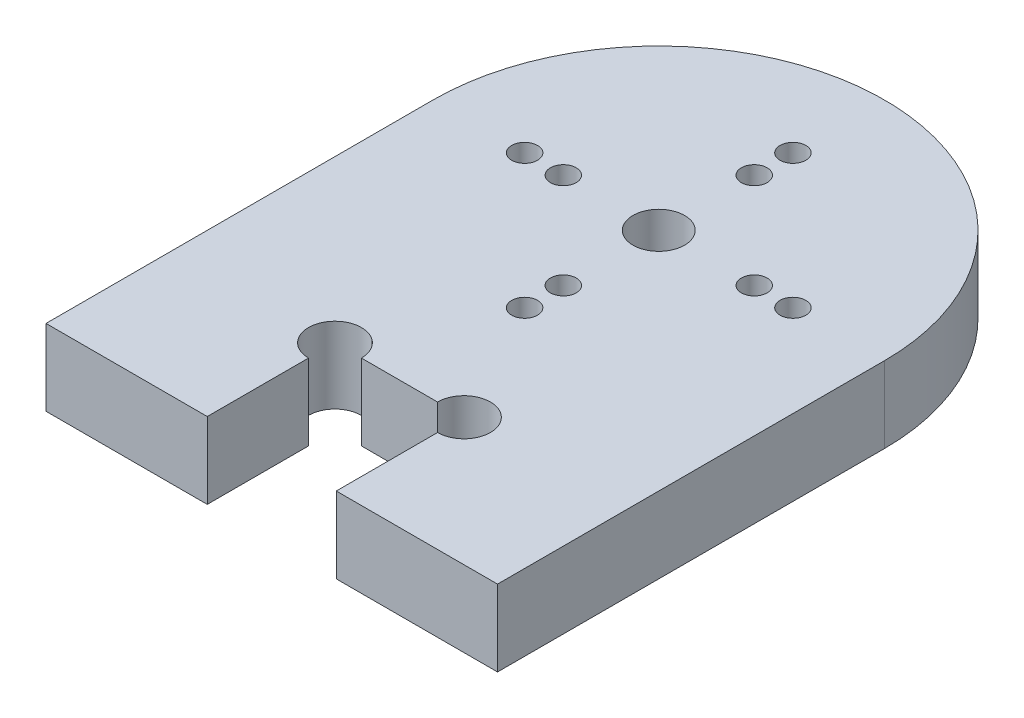
from build123d import *

# Parameters (mm, degrees)
SKETCH1_R           = 1
BOSS_EXTRUDE1_DEPTH = 5.9
SKETCH2_W           = 10
SKETCH2_H           = 11.8
CUT_EXTRUDE1_DEPTH  = 10
SKETCH3_W           = 12.5
SKETCH3_H           = 5.9
BOSS_EXTRUDE2_DEPTH = 5
CUT_EXTRUDE2_REACH  = 7.9
SKETCH4_R           = 2.05


with BuildPart() as part:
    # Sketch1 → Boss-Extrude1 (new body)
    with BuildSketch(Plane(origin=(0, 0, 0), x_dir=(1, 0, 0), z_dir=(0, 1, 0))):
        with BuildLine():
            ThreePointArc((9.4, 12.5), (10.4, 13.5), (11.4, 12.5))
            Line((11.4, 12.5), (17.5, 12.5))
            ThreePointArc((17.5, 12.5), (0, 30), (-17.5, 12.5))
            Line((-17.5, 12.5), (-11.4, 12.5))
            ThreePointArc((-11.4, 12.5), (-10.4, 13.5), (-9.4, 12.5))
            Line((-9.4, 12.5), (-8.4, 12.5))
            ThreePointArc((-8.4, 12.5), (-7.4, 13.5), (-6.4, 12.5))
            Line((-6.4, 12.5), (-2, 12.5))
            ThreePointArc((-2, 12.5), (0, 14.5), (2, 12.5))
            Line((2, 12.5), (6.4, 12.5))
            ThreePointArc((6.4, 12.5), (7.4, 13.5), (8.4, 12.5))
            Line((8.4, 12.5), (9.4, 12.5))
        make_face()
        with Locations((0, 19.9)):
            Circle(SKETCH1_R, mode=Mode.SUBTRACT)
        with Locations((0, 22.9)):
            Circle(SKETCH1_R, mode=Mode.SUBTRACT)
        with BuildLine():
            Line((17.5, 12.5), (11.4, 12.5))
            ThreePointArc((11.4, 12.5), (10.4, 11.5), (9.4, 12.5))
            Line((9.4, 12.5), (8.4, 12.5))
            ThreePointArc((8.4, 12.5), (7.4, 11.5), (6.4, 12.5))
            Line((6.4, 12.5), (2, 12.5))
            ThreePointArc((2, 12.5), (0, 10.5), (-2, 12.5))
            Line((-2, 12.5), (-6.4, 12.5))
            ThreePointArc((-6.4, 12.5), (-7.4, 11.5), (-8.4, 12.5))
            Line((-8.4, 12.5), (-9.4, 12.5))
            ThreePointArc((-9.4, 12.5), (-10.4, 11.5), (-11.4, 12.5))
            Line((-11.4, 12.5), (-17.5, 12.5))
            ThreePointArc((-17.5, 12.5), (0, -5), (17.5, 12.5))
        make_face()
        with Locations((0, 2.1)):
            Circle(SKETCH1_R, mode=Mode.SUBTRACT)
        with Locations((0, 5.1)):
            Circle(SKETCH1_R, mode=Mode.SUBTRACT)
        with BuildLine():
            Line((17.5, -12.5), (17.5, 12.5))
            ThreePointArc((17.5, 12.5), (0, -5), (-17.5, 12.5))
            Line((-17.5, 12.5), (-17.5, -12.5))
            Line((-17.5, -12.5), (17.5, -12.5))
        make_face()
    extrude(amount=BOSS_EXTRUDE1_DEPTH)

    # Sketch2 → Cut-Extrude1 (cut)
    with BuildSketch(Plane(origin=(0, 5.9, 0), x_dir=(1, 0, 0), z_dir=(0, 1, 0))):
        with Locations((0, -13.5)):
            Rectangle(SKETCH2_W, SKETCH2_H)
    extrude(amount=-CUT_EXTRUDE1_DEPTH, mode=Mode.SUBTRACT)

    # Sketch3 → Boss-Extrude2 (add)
    with BuildSketch(Plane.XY.offset(12.5)):
        with Locations((-11.25, 2.95)):
            Rectangle(SKETCH3_W, SKETCH3_H)
        with Locations((11.25, 2.95)):
            Rectangle(SKETCH3_W, SKETCH3_H)
    extrude(amount=BOSS_EXTRUDE2_DEPTH)

    # Sketch4 → Cut-Extrude2 (cut, up to next)
    with BuildSketch(Plane(origin=(0, 5.9, 0), x_dir=(1, 0, 0), z_dir=(0, 1, 0)), mode=Mode.PRIVATE) as cut_extrude2_sk1:
        with Locations((-5, -7.6)):
            Circle(SKETCH4_R)
    cut_extrude2_tool1 = extrude(cut_extrude2_sk1.sketch, amount=-CUT_EXTRUDE2_REACH, mode=Mode.PRIVATE) & part.part
    add(cut_extrude2_tool1.solids().sort_by_distance((-5, 5.9, 7.6))[0], mode=Mode.SUBTRACT)
    # Sketch4 → Cut-Extrude2 (cut, up to next)
    with BuildSketch(Plane(origin=(0, 5.9, 0), x_dir=(1, 0, 0), z_dir=(0, 1, 0)), mode=Mode.PRIVATE) as cut_extrude2_sk2:
        with Locations((5, -7.6)):
            Circle(SKETCH4_R)
    cut_extrude2_tool2 = extrude(cut_extrude2_sk2.sketch, amount=-CUT_EXTRUDE2_REACH, mode=Mode.PRIVATE) & part.part
    add(cut_extrude2_tool2.solids().sort_by_distance((5, 5.9, 7.6))[0], mode=Mode.SUBTRACT)


solid = part.part
